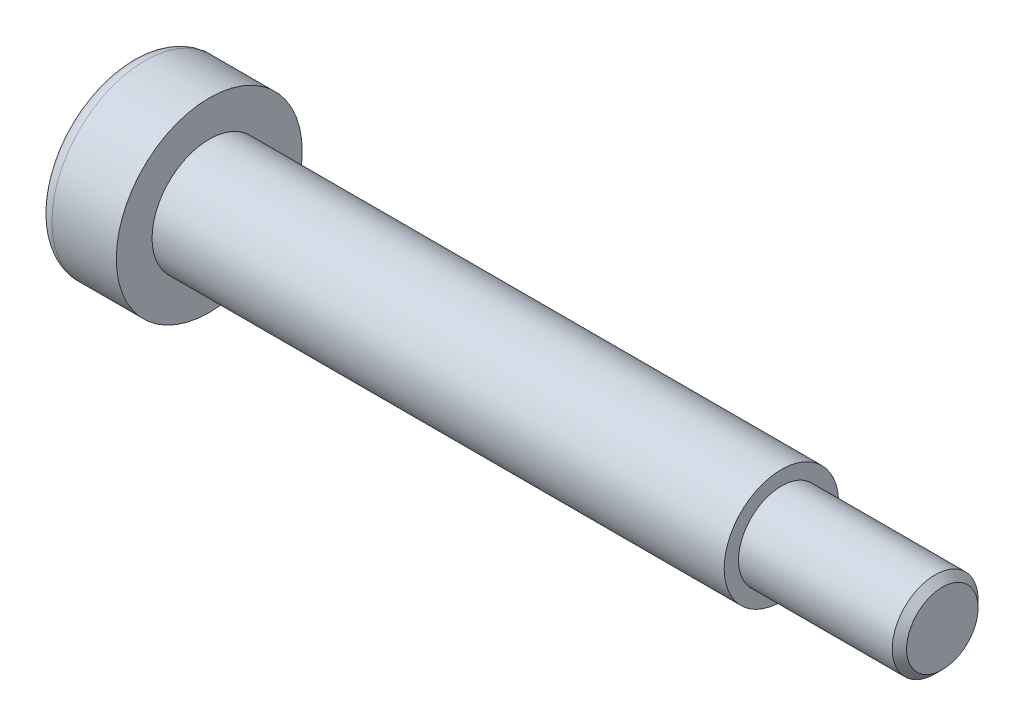
from build123d import *

# Parameters (mm, degrees)
CUT_EXTRUDE_1_DEPTH = 3.3
FILLET_1_R          = 1
CHAMFER_1_SIZE      = 0.5


with BuildPart() as part:
    # 草图1 → 旋转1 (revolve)
    with BuildSketch(Plane.XY):
        Polygon((0, 0), (0, 6.5), (5.5, 6.5), (5.5, 4), (45.5, 4), (45.5, 3), (56.75, 3), (56.75, 0), align=None)
    revolve(axis=Axis((0, 0, 0), (1, 0, 0)))

    # 草图2 → 切除-拉伸1 (cut)
    with BuildSketch(Plane.ZY):
        Polygon((0, 2.309401077), (-2, 1.154700538), (-2, -1.154700538), (0, -2.309401077), (2, -1.154700538), (2, 1.154700538), align=None)
    extrude(amount=-CUT_EXTRUDE_1_DEPTH, mode=Mode.SUBTRACT)

    # 圆角1
    fillet_1_edges = [part.edges().sort_by_distance(p)[0] for p in [
        (0, -6.5, 0),
    ]]
    fillet(fillet_1_edges, radius=FILLET_1_R)

    # 倒角1
    chamfer_1_edges = [part.edges().sort_by_distance(p)[0] for p in [
        (56.75, -3, 0),
    ]]
    chamfer(chamfer_1_edges, length=CHAMFER_1_SIZE)


solid = part.part
